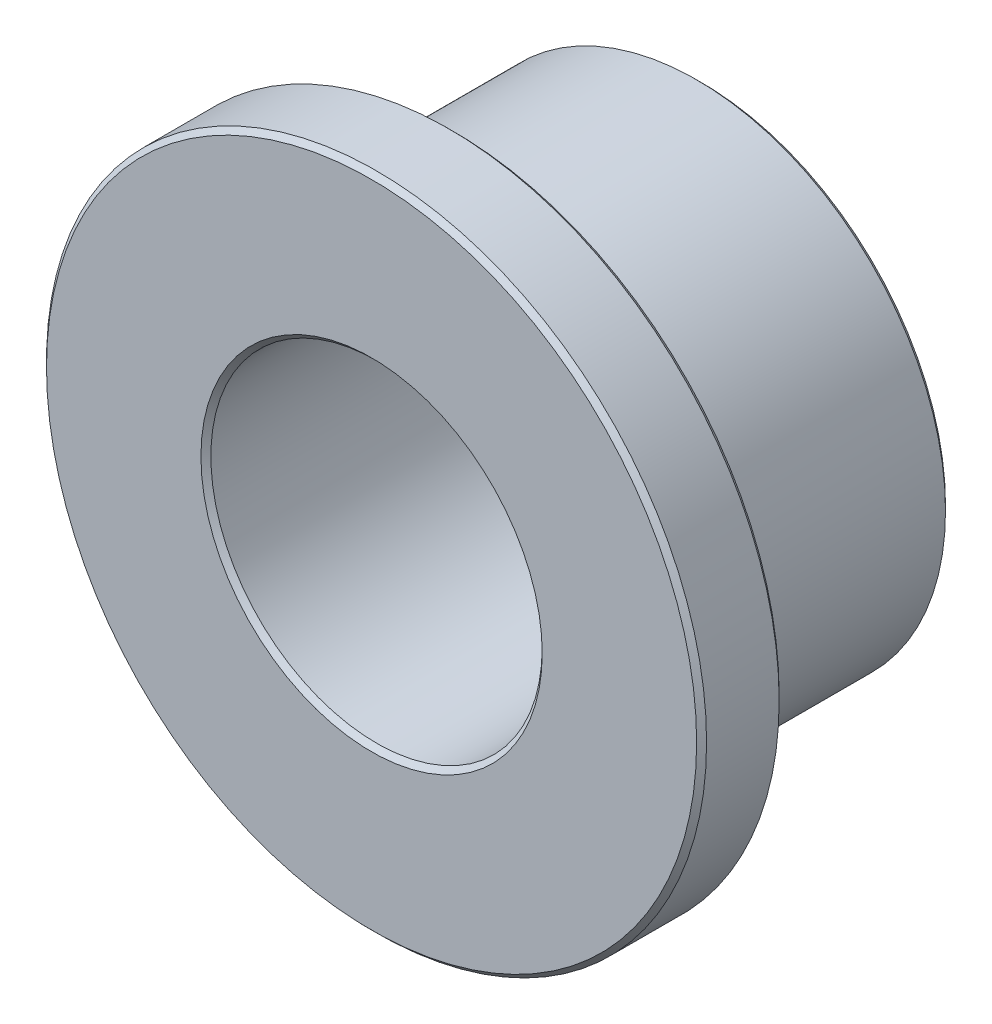
from build123d import *

# Parameters (mm, degrees)
BOSS_EXTRUDE1_START = 3.175
SKETCH3_R           = 6.35
SKETCH3_R_2         = 3.1877
BOSS_EXTRUDE1_DEPTH = 1.5875
BOSS_EXTRUDE2_START = 1.5875
SKETCH4_R           = 4.7879
SKETCH4_R_2         = 3.1877
BOSS_EXTRUDE2_DEPTH = 4.7625
CHAMFER1_SIZE       = 0.095631


with BuildPart() as part:
    # Sketch3 → Boss-Extrude1 (new body)
    with BuildSketch(Plane.XY.offset(BOSS_EXTRUDE1_START)):
        Circle(SKETCH3_R)
        Circle(SKETCH3_R_2, mode=Mode.SUBTRACT)
    extrude(amount=-BOSS_EXTRUDE1_DEPTH)

    # Sketch4 → Boss-Extrude2 (add)
    with BuildSketch(Plane.XY.offset(BOSS_EXTRUDE2_START)):
        Circle(SKETCH4_R)
        Circle(SKETCH4_R_2, mode=Mode.SUBTRACT)
    extrude(amount=-BOSS_EXTRUDE2_DEPTH)

    # Chamfer1
    chamfer1_edges = [part.edges().sort_by_distance(p)[0] for p in [
        (-3.1877, 0, -3.175),
        (-4.7879, 0, 1.5875),
        (-6.35, 0, 3.175),
        (-6.35, 0, 1.5875),
        (-3.1877, 0, 3.175),
        (-4.7879, 0, -3.175),
    ]]
    chamfer(chamfer1_edges, length=CHAMFER1_SIZE)


solid = part.part
